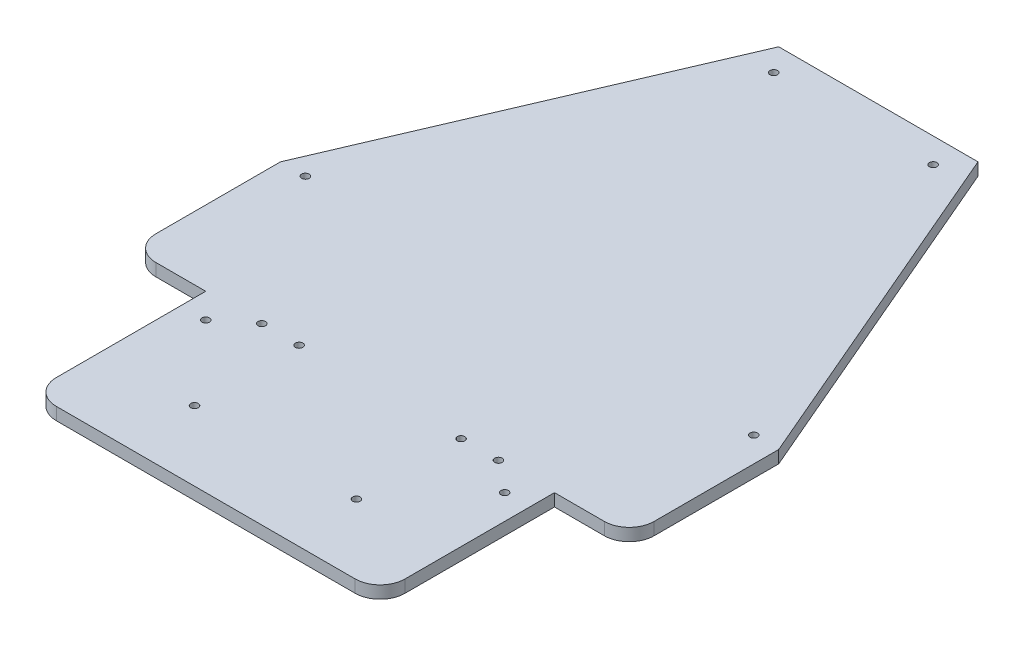
from build123d import *

# Parameters (mm, degrees)
SKETCH1_R           = 1.5
BOSS_EXTRUDE1_DEPTH = 5
SKETCH8_R           = 1.5
CUT_EXTRUDE5_DEPTH  = 10
SKETCH9_R           = 1.5
CUT_EXTRUDE6_DEPTH  = 10


with BuildPart() as part:
    # Sketch1 → Boss-Extrude1 (new body)
    with BuildSketch(Plane(origin=(0, 0, 0), x_dir=(1, 0, 0), z_dir=(0, 1, 0))):
        with BuildLine():
            Line((100, -40), (100, 10))
            Line((100, 10), (40, 150))
            Line((40, 150), (-40, 150))
            Line((-40, 150), (-100, 10))
            Line((-100, 10), (-100, -40))
            ThreePointArc((-100, -40), (-97.071067812, -47.071067812), (-90, -50))
            Line((-90, -50), (-70, -50))
            Line((-70, -50), (-70, -60))
            Line((-70, -60), (-70, -110))
            ThreePointArc((-70, -110), (-67.071067812, -117.071067812), (-60, -120))
            Line((-60, -120), (60, -120))
            ThreePointArc((60, -120), (67.071067812, -117.071067812), (70, -110))
            Line((70, -110), (70, -60))
            Line((70, -60), (70, -50))
            Line((70, -50), (90, -50))
            ThreePointArc((90, -50), (97.071067812, -47.071067812), (100, -40))
        make_face()
        with Locations((-60, -60)):
            Circle(SKETCH1_R, mode=Mode.SUBTRACT)
        with Locations((60, -60)):
            Circle(SKETCH1_R, mode=Mode.SUBTRACT)
    extrude(amount=BOSS_EXTRUDE1_DEPTH)

    # Sketch8 → Cut-Extrude5 (cut)
    with BuildSketch(Plane(origin=(0, 5, 0), x_dir=(1, 0, 0), z_dir=(0, 1, 0))):
        with Locations((-90, 10)):
            Circle(SKETCH8_R)
        with Locations((-32, 140)):
            Circle(SKETCH8_R)
        with Locations((90, 10)):
            Circle(SKETCH8_R)
        with Locations((32, 140)):
            Circle(SKETCH8_R)
    extrude(amount=-CUT_EXTRUDE5_DEPTH, mode=Mode.SUBTRACT)

    # Sketch9 → Cut-Extrude6 (cut)
    with BuildSketch(Plane(origin=(0, 5, 0), x_dir=(1, 0, 0), z_dir=(0, 1, 0))):
        with Locations((47.5, -50)):
            Circle(SKETCH9_R)
        with Locations((32.5, -50)):
            Circle(SKETCH9_R)
        with Locations((32.5, -92)):
            Circle(SKETCH9_R)
        with Locations((-32.5, -50)):
            Circle(SKETCH9_R)
        with Locations((-32.5, -92)):
            Circle(SKETCH9_R)
        with Locations((-47.5, -50)):
            Circle(SKETCH9_R)
    extrude(amount=-CUT_EXTRUDE6_DEPTH, mode=Mode.SUBTRACT)


solid = part.part
